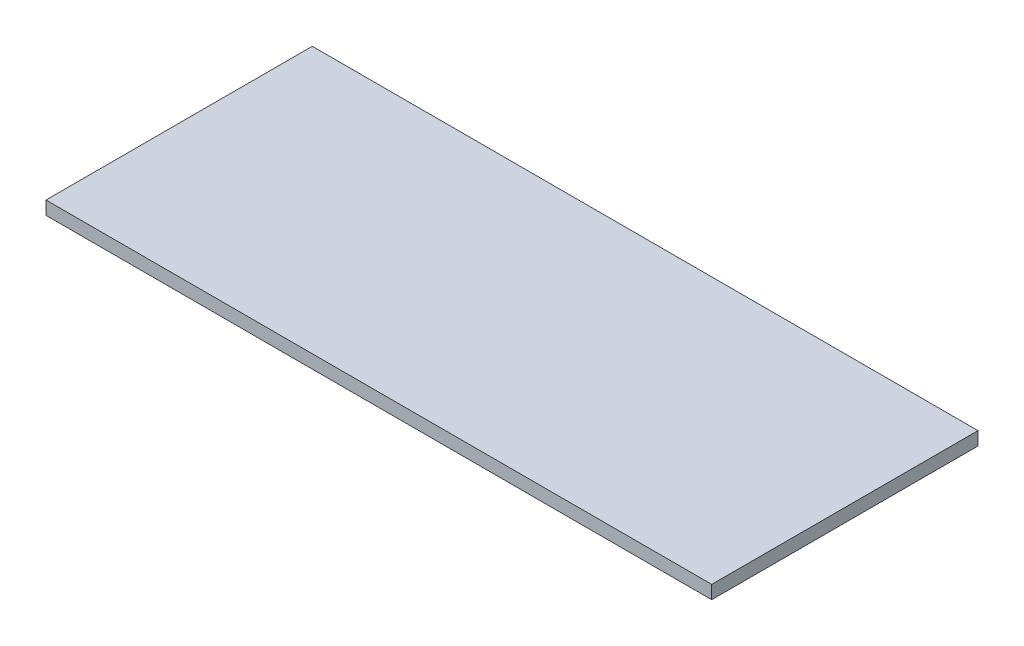
from build123d import *

# Parameters (mm, degrees)
SKETCH1_W           = 1500
SKETCH1_H           = 600
BOSS_EXTRUDE1_DEPTH = 30


with BuildPart() as part:
    # Sketch1 → Boss-Extrude1 (new body)
    with BuildSketch(Plane(origin=(0, 0, 0), x_dir=(1, 0, 0), z_dir=(0, 1, 0))):
        with Locations((0, -245.52715655)):
            Rectangle(SKETCH1_W, SKETCH1_H)
    extrude(amount=BOSS_EXTRUDE1_DEPTH)


solid = part.part
